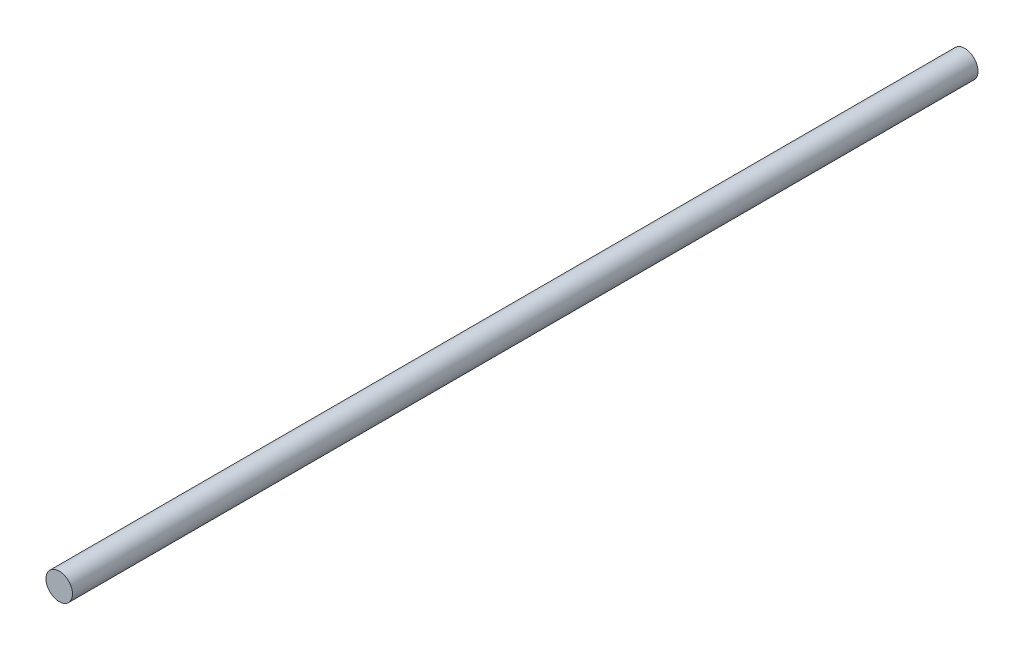
from build123d import *

# Parameters (mm, degrees)
SKETCH1_R           = 3
BOSS_EXTRUDE1_DEPTH = 205


with BuildPart() as part:
    # Sketch1 → Boss-Extrude1 (new body)
    with BuildSketch(Plane.XY):
        Circle(SKETCH1_R)
    extrude(amount=BOSS_EXTRUDE1_DEPTH)


solid = part.part
